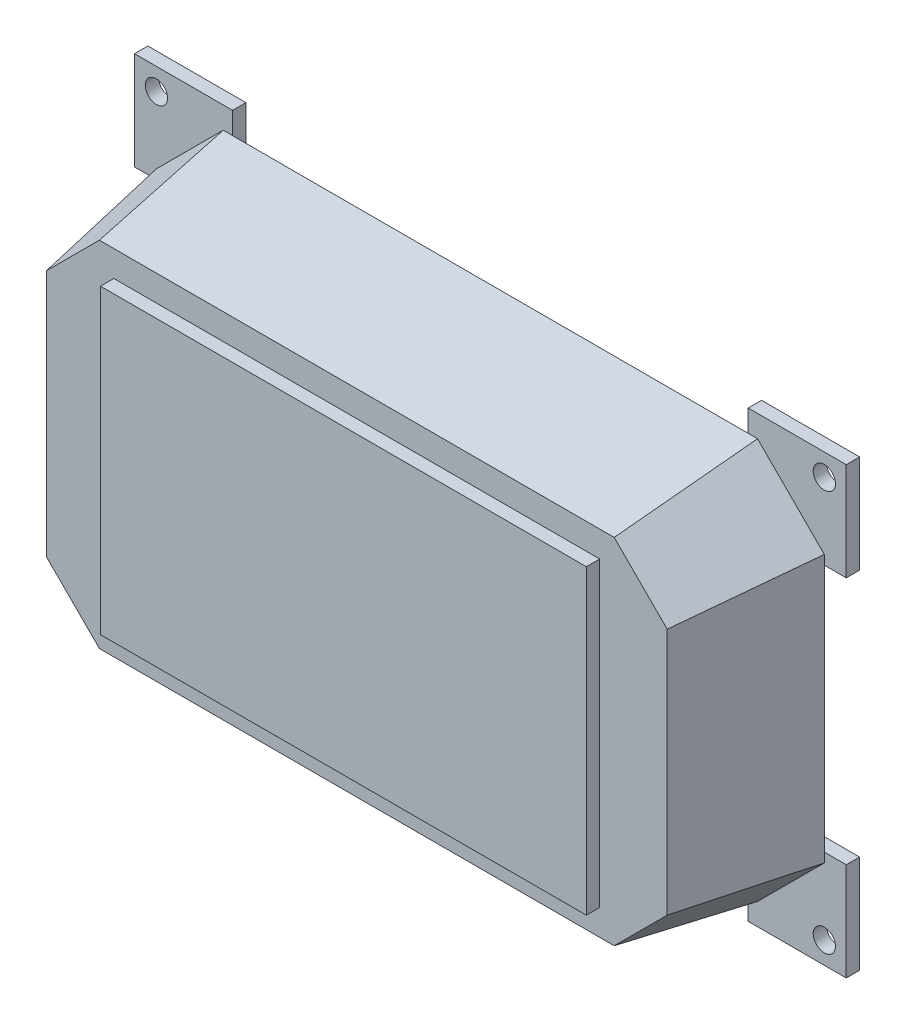
from build123d import *

# Parameters (mm, degrees)
BOSS_EXTRUDE1_DEPTH     = 30
BOSS_EXTRUDE1_TAPER     = 10
SHELL1_T                = -5
SKETCH4_R               = 1.5
CUT_EXTRUDE1_DEPTH      = 15
SKETCH5_W               = 109.114976024
SKETCH5_H               = 67.775815427
BOSS_EXTRUDE3_DEPTH     = 3
BOSS_EXTRUDE5_DEPTH     = 3
MIRROR5_COPY_1_DEPTH    = 3
CUT_EXTRUDE2_START      = -4
SKETCH9_R               = 2.5
CUT_EXTRUDE2_DEPTH      = 38
MIRROR7_START           = -4
MIRROR7_COPY_1_SKETCH_R = 2.5
MIRROR7_COPY_1_DEPTH    = 38


with BuildPart() as part:
    # Sketch1 → Boss-Extrude1 (new body)
    with BuildSketch(Plane.XY):
        Polygon((-100, 10.531931481), (-100, -49.468068519), (-85, -64.468068519), (35, -64.468068519), (50, -49.468068519), (50, 10.531931481), (35, 25.531931481), (-85, 25.531931481), align=None)
    extrude(amount=BOSS_EXTRUDE1_DEPTH, taper=BOSS_EXTRUDE1_TAPER)

    # Shell1
    shell1_openings = [part.faces().sort_by_distance(p)[0] for p in [
        (-25, -19.468068519, 0),
    ]]
    offset(amount=SHELL1_T, openings=shell1_openings, kind=Kind.INTERSECTION)

    # Sketch4 → Cut-Extrude1 (cut)
    with BuildSketch(Plane(origin=(0, 0, -7), x_dir=(-1, 0, 0), z_dir=(0, 0, -1))):
        with Locations((-24.758515909, -65.141240386)):
            Circle(SKETCH4_R)
    cut_extrude1 = extrude(amount=-CUT_EXTRUDE1_DEPTH, mode=Mode.SUBTRACT)

    # Mirror1: Cut-Extrude1 across plane
    add(cut_extrude1.mirror(Plane(origin=(-26.029584976, 0, 0), x_dir=(0, 0, 1), z_dir=(1, 0, 0))), mode=Mode.SUBTRACT)

    # Sketch5 → Boss-Extrude3 (add)
    with BuildSketch(Plane.XY.offset(30)):
        with Locations((-25, -19.468068519)):
            Rectangle(SKETCH5_W, SKETCH5_H)
    extrude(amount=BOSS_EXTRUDE3_DEPTH)

    # Sketch8 → Boss-Extrude5 (add)
    with BuildSketch(Plane(origin=(0, 0, 0), x_dir=(-1, 0, 0), z_dir=(0, 0, -1))):
        Polygon((-54.922866941, 8.42891411), (-44.922866941, 8.42891411), (-32.896982629, 20.454798422), (-32.896982629, 30.454798422), (-54.922866941, 30.454798422), align=None)
    boss_extrude5 = extrude(amount=BOSS_EXTRUDE5_DEPTH)

    # Mirror4: Boss-Extrude5 across plane
    add(boss_extrude5.mirror(Plane.ZY.offset(25)))

    # Mirror5: Boss-Extrude5 across plane
    add(boss_extrude5.mirror(Plane.ZX.offset(-19.468068519)))

    # Mirror5 copy 1 sketch → Mirror5 copy 1 (add)
    with BuildSketch(Plane(origin=(-50, -38.936137038, 0), x_dir=(1, 0, 0), z_dir=(0, 0, -1))):
        Polygon((-54.922866941, 8.42891411), (-44.922866941, 8.42891411), (-32.896982629, 20.454798422), (-32.896982629, 30.454798422), (-54.922866941, 30.454798422), align=None)
    extrude(amount=MIRROR5_COPY_1_DEPTH)

    # Sketch9 → Cut-Extrude2 (cut)
    with BuildSketch(Plane.XY.offset(CUT_EXTRUDE2_START)):
        with Locations((50, -64.468068519)):
            Circle(SKETCH9_R)
    cut_extrude2 = extrude(amount=CUT_EXTRUDE2_DEPTH, mode=Mode.SUBTRACT)

    # Mirror6: Cut-Extrude2 across plane
    add(cut_extrude2.mirror(Plane.ZY.offset(25)), mode=Mode.SUBTRACT)

    # Mirror7: Cut-Extrude2 across plane
    add(cut_extrude2.mirror(Plane.ZX.offset(-19.468068519)), mode=Mode.SUBTRACT)

    # Mirror7 copy 1 sketch → Mirror7 copy 1 (cut)
    with BuildSketch(Plane(origin=(-50, -38.936137038, 0), x_dir=(-1, 0, 0), z_dir=(0, 0, 1)).offset(MIRROR7_START)):
        with Locations((50, -64.468068519)):
            Circle(MIRROR7_COPY_1_SKETCH_R)
    extrude(amount=MIRROR7_COPY_1_DEPTH, mode=Mode.SUBTRACT)


solid = part.part
